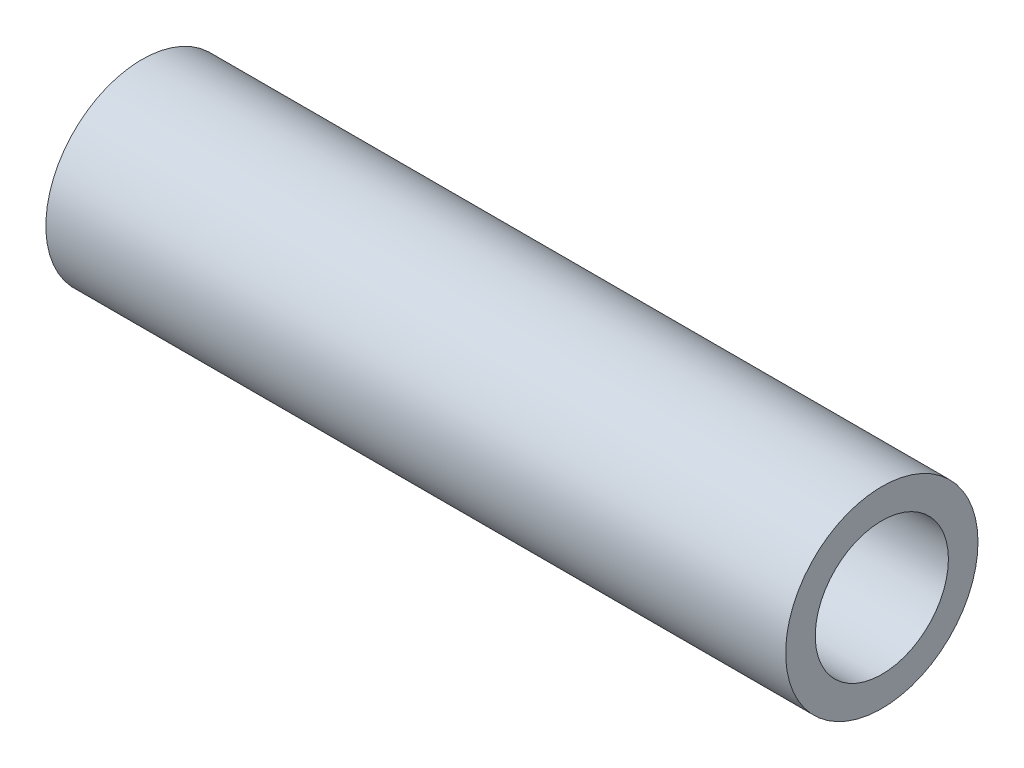
from build123d import *

# Parameters (mm, degrees)
SKETCH_1_R      = 13
SKETCH_1_R_2    = 9
EXTRUDE_1_DEPTH = 100


with BuildPart() as part:
    # Эскиз1 → Бобышка-Вытянуть1 (new body)
    with BuildSketch(Plane(origin=(0, 0, 0), x_dir=(0, 0, -1), z_dir=(1, 0, 0))):
        Circle(SKETCH_1_R)
        Circle(SKETCH_1_R_2, mode=Mode.SUBTRACT)
    extrude(amount=EXTRUDE_1_DEPTH)


solid = part.part
